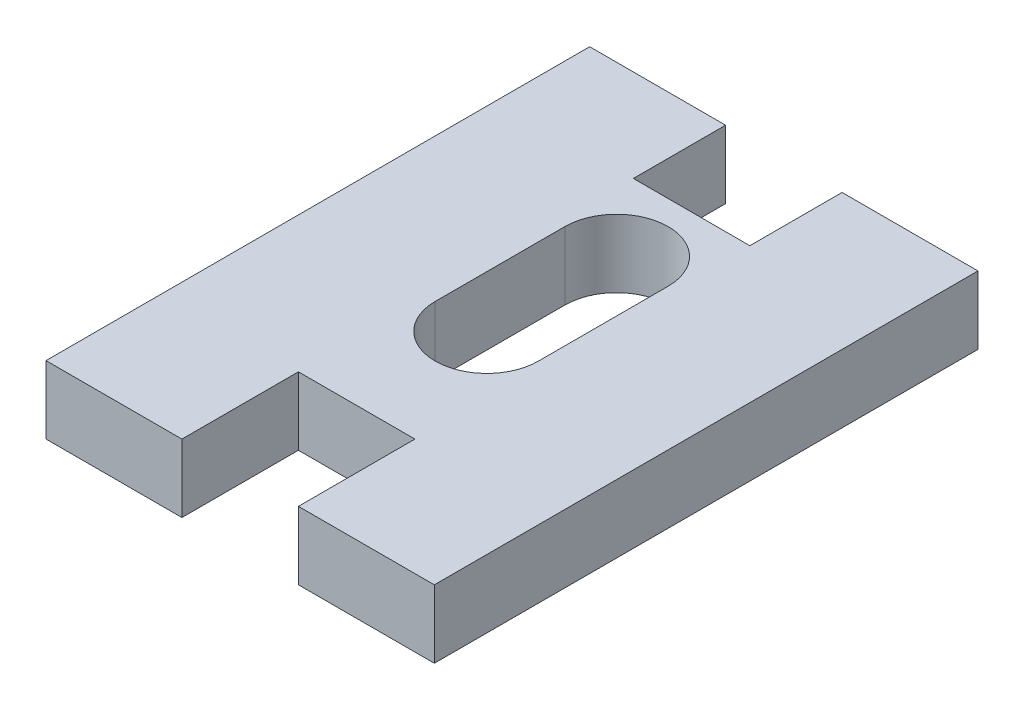
from build123d import *

# Parameters (mm, degrees)
SKETCH1_W           = 20
SKETCH1_H           = 28
BOSS_EXTRUDE1_DEPTH = 3.5
SKETCH2_W           = 6
SKETCH2_H           = 4.75
SKETCH2_H_2         = 6
CUT_EXTRUDE1_DEPTH  = 4.5
CUT_EXTRUDE6_DEPTH  = 4.5


with BuildPart() as part:
    # Sketch1 → Boss-Extrude1 (new body)
    with BuildSketch(Plane(origin=(0, 0, 0), x_dir=(1, 0, 0), z_dir=(0, 1, 0))):
        with Locations((10, 14)):
            Rectangle(SKETCH1_W, SKETCH1_H)
    extrude(amount=BOSS_EXTRUDE1_DEPTH)

    # Sketch2 → Cut-Extrude1 (cut, through all)
    with BuildSketch(Plane(origin=(0, 3.5, 0), x_dir=(1, 0, 0), z_dir=(0, 1, 0))):
        with Locations((10, 25.625)):
            Rectangle(SKETCH2_W, SKETCH2_H)
        with Locations((10, 3)):
            Rectangle(SKETCH2_W, SKETCH2_H_2)
    extrude(amount=-CUT_EXTRUDE1_DEPTH, mode=Mode.SUBTRACT)

    # Sketch4 → Cut-Extrude6 (cut, through all)
    with BuildSketch(Plane(origin=(0, 3.5, 0), x_dir=(1, 0, 0), z_dir=(0, 1, 0))):
        with BuildLine():
            Line((12.702975316, 19.34), (12.702975316, 12.66))
            ThreePointArc((12.702975316, 12.66), (10.042975316, 10), (7.382975316, 12.66))
            Line((7.382975316, 12.66), (7.382975316, 19.34))
            ThreePointArc((7.382975316, 19.34), (10.042975316, 22), (12.702975316, 19.34))
        make_face()
    extrude(amount=-CUT_EXTRUDE6_DEPTH, mode=Mode.SUBTRACT)


solid = part.part
